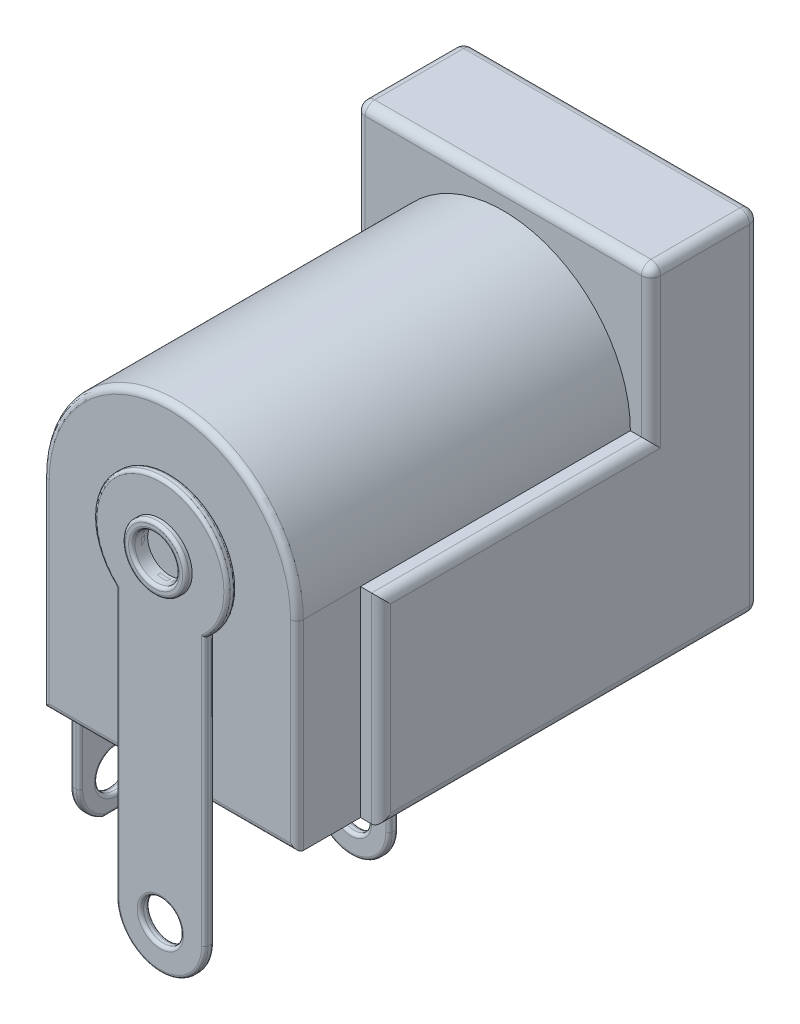
from build123d import *

# Parameters (mm, degrees)
SZKIC1_W                    = 9.3
SZKIC1_H                    = 11
DODANIE_WYCI_GNI_CIE1_DEPTH = 13.9
SZKIC2_W                    = 2.749255813
SZKIC2_H                    = 13.524079228
WYTNIJ_WYCI_GNI_CIE1_DEPTH  = 0.65
WYTNIJ_WYCI_GNI_CIE2_DEPTH  = 10.5
SZKIC4_R                    = 3.55
WYTNIJ_WYCI_GNI_CIE3_DEPTH  = 11.9
SZKIC5_R                    = 0.63
SZKIC5_R_2                  = 0.7
DODANIE_WYCI_GNI_CIE2_DEPTH = 0.3
SZKIC6_R                    = 1
DODANIE_WYCI_GNI_CIE3_DEPTH = 10
ZAOKR_GLENIE1_R             = 0.4
DODANIE_WYCI_GNI_CIE4_DEPTH = 1.3
ZAOKR_GLENIE2_R             = 0.5
ZAOKR_GLENIE3_R             = 0.3
ZAOKR_GLENIE4_R             = 0.2
ZAOKR_GLENIE5_R             = 0.1
SZKIC8_R                    = 1
SZKIC8_R_2                  = 0.7
DODANIE_WYCI_GNI_CIE5_DEPTH = 0.5
ZAOKR_GLENIE6_R             = 0.1
SZKIC9_R                    = 0.63
DODANIE_WYCI_GNI_CIE6_DEPTH = 0.3
ZAOKR_GLENIE7_R             = 0.1
DODANIE_WYCI_GNI_CIE7_DEPTH = 20.3
SZKIC11_OUTSIDE_W           = 27.84
SZKIC11_OUTSIDE_H           = 23.64
SZKIC11_OUTSIDE_R           = 0.63
WYTNIJ_WYCI_GNI_CIE4_DEPTH  = 20.3
ZAOKR_GLENIE8_R             = 0.1


with BuildPart() as part:
    # Szkic1 → Dodanie-wyciągnięcie1 (new body)
    with BuildSketch(Plane.XY):
        Rectangle(SZKIC1_W, SZKIC1_H)
    extrude(amount=DODANIE_WYCI_GNI_CIE1_DEPTH)

    # Szkic2 → Wytnij-wyciągnięcie1 (cut)
    with BuildSketch(Plane(origin=(4.65, 0, 0), x_dir=(0, 0, -1), z_dir=(1, 0, 0))):
        with Locations((-13.274627907, 1.262039614)):
            Rectangle(SZKIC2_W, SZKIC2_H)
    wytnij_wyci_gni_cie1 = extrude(amount=-WYTNIJ_WYCI_GNI_CIE1_DEPTH, mode=Mode.SUBTRACT)

    # Lustro1: Wytnij-wyciągnięcie1 across plane
    add(wytnij_wyci_gni_cie1.mirror(Plane(origin=(0, 0, 0), x_dir=(0, 0, 1), z_dir=(1, 0, 0))), mode=Mode.SUBTRACT)

    # Szkic3 → Wytnij-wyciągnięcie2 (cut)
    with BuildSketch(Plane.XY.offset(13.9)):
        with BuildLine():
            Line((-4, 0.8), (-6.611766209, 0.8))
            Line((-6.611766209, 0.8), (-6.611766209, 8.429628799))
            Line((-6.611766209, 8.429628799), (6.415013524, 8.429628799))
            Line((6.415013524, 8.429628799), (6.415013524, 0.8))
            Line((6.415013524, 0.8), (4, 0.8))
            ThreePointArc((4, 0.8), (0, 4.8), (-4, 0.8))
        make_face()
    extrude(amount=-WYTNIJ_WYCI_GNI_CIE2_DEPTH, mode=Mode.SUBTRACT)

    # Szkic4 → Wytnij-wyciągnięcie3 (cut)
    with BuildSketch(Plane(origin=(0, 0, 0), x_dir=(-1, 0, 0), z_dir=(0, 0, -1))):
        with Locations((0, 0.8)):
            Circle(SZKIC4_R)
    extrude(amount=-WYTNIJ_WYCI_GNI_CIE3_DEPTH, mode=Mode.SUBTRACT)

    # Zaokrąglenie2
    zaokr_glenie2_edges = [part.edges().sort_by_distance(p)[0] for p in [
        (3.55, 0.8, 0),
    ]]
    fillet(zaokr_glenie2_edges, radius=ZAOKR_GLENIE2_R)

    # Zaokrąglenie3
    zaokr_glenie3_edges = [part.edges().sort_by_distance(p)[0] for p in [
        (4.65, -5.5, 5.95),
        (4.65, -2.35, 11.9),
        (-4.65, -5.5, 5.95),
        (-4.65, -2.35, 11.9),
        (0, 5.5, 0),
        (4.65, 0, 0),
        (0, -5.5, 0),
        (-4.65, 0, 0),
        (4.65, 5.5, 1.7),
        (4.65, 3.15, 3.4),
        (-4.65, 5.5, 1.7),
        (4.65, 0.8, 7.65),
        (-4.65, 0.8, 7.65),
        (0, 5.5, 3.4),
        (-4.65, 3.15, 3.4),
    ]]
    fillet(zaokr_glenie3_edges, radius=ZAOKR_GLENIE3_R)

    # Zaokrąglenie4
    zaokr_glenie4_edges = [part.edges().sort_by_distance(p)[0] for p in [
        (0, -5.5, 13.9),
        (-4, -2.35, 13.9),
        (4, -2.35, 13.9),
        (0, 4.8, 13.9),
    ]]
    fillet(zaokr_glenie4_edges, radius=ZAOKR_GLENIE4_R)

    # Szkic8 → Dodanie-wyciągnięcie5 (add)
    with BuildSketch(Plane.XY.offset(13.9)):
        with Locations((0, 0.8)):
            Circle(SZKIC8_R)
        with Locations((0, 0.8)):
            Circle(SZKIC8_R_2, mode=Mode.SUBTRACT)
    extrude(amount=DODANIE_WYCI_GNI_CIE5_DEPTH)

    # Zaokrąglenie6
    zaokr_glenie6_edges = [part.edges().sort_by_distance(p)[0] for p in [
        (-1, 0.8, 14.4),
        (-0.7, 0.8, 14.4),
    ]]
    fillet(zaokr_glenie6_edges, radius=ZAOKR_GLENIE6_R)


with BuildPart() as body_2:
    # Szkic5 → Dodanie-wyciągnięcie2 (new body)
    with BuildSketch(Plane.XY.offset(13.9)):
        with BuildLine():
            Line((1.4, -5.5), (-1.4, -5.5))
            Line((-1.4, -5.5), (-1.4, -9.2))
            ThreePointArc((-1.4, -9.2), (0, -10.6), (1.4, -9.2))
            Line((1.4, -9.2), (1.4, -5.5))
        make_face()
        with Locations((0, -9.2)):
            Circle(SZKIC5_R, mode=Mode.SUBTRACT)
        with BuildLine():
            ThreePointArc((1.4, -0.765247584), (0, 2.9), (-1.4, -0.765247584))
            Line((-1.4, -0.765247584), (-1.4, -5.5))
            Line((-1.4, -5.5), (1.4, -5.5))
            Line((1.4, -5.5), (1.4, -0.765247584))
        make_face()
        with Locations((0, 0.8)):
            Circle(SZKIC5_R_2, mode=Mode.SUBTRACT)
    extrude(amount=DODANIE_WYCI_GNI_CIE2_DEPTH)

    # Zaokrąglenie5
    zaokr_glenie5_edges = [body_2.edges().sort_by_distance(p)[0] for p in [
        (-1.4, -4.982623792, 13.9),
        (-0.63, -9.2, 13.9),
        (-1.4, -4.982623792, 14.2),
        (0, -10.6, 14.2),
        (1.4, -4.982623792, 14.2),
        (0, 2.9, 14.2),
        (-0.7, 0.8, 14.2),
        (-0.63, -9.2, 14.2),
        (-0.7, 0.8, 13.9),
        (0, 2.9, 13.9),
        (1.4, -4.982623792, 13.9),
        (0, -10.6, 13.9),
    ]]
    fillet(zaokr_glenie5_edges, radius=ZAOKR_GLENIE5_R)


with BuildPart() as body_3:
    # Szkic6 → Dodanie-wyciągnięcie3 (new body)
    with BuildSketch(Plane(origin=(0, 0, 11.9), x_dir=(-1, 0, 0), z_dir=(0, 0, -1))):
        with Locations((0, 0.8)):
            Circle(SZKIC6_R)
    extrude(amount=DODANIE_WYCI_GNI_CIE3_DEPTH)

    # Zaokrąglenie1
    zaokr_glenie1_edges = [body_3.edges().sort_by_distance(p)[0] for p in [
        (1, 0.8, 1.9),
    ]]
    fillet(zaokr_glenie1_edges, radius=ZAOKR_GLENIE1_R)


with BuildPart() as body_4:
    # Szkic7 → Dodanie-wyciągnięcie4 (new body, symmetric)
    with BuildSketch(Plane(origin=(0, 0, 0), x_dir=(0, 0, -1), z_dir=(1, 0, 0))):
        with BuildLine():
            Line((-2.4, -1.451343329), (-2.4, -1.574639266))
            ThreePointArc((-2.4, -1.574639266), (-2.445080666, -1.701130372), (-2.56, -1.770598445))
            ThreePointArc((-2.56, -1.770598445), (-2.580211742, -1.769131782), (-2.6, -1.764762524))
            ThreePointArc((-2.6, -1.764762524), (-2.672249722, -1.714264448), (-2.7, -1.630598445))
            Line((-2.7, -1.630598445), (-2.7, -1.575949306))
            Line((-2.7, -1.575949306), (-5.15, -1.065247584))
            Line((-5.15, -1.065247584), (-7.6, -1.575949306))
            Line((-7.6, -1.575949306), (-7.6, -1.909704781))
            Line((-7.6, -1.909704781), (-7.9, -1.909704781))
            Line((-7.9, -1.909704781), (-7.9, -1.480474967))
            Line((-7.9, -1.480474967), (-7.9, -1.337476183))
            Line((-7.9, -1.337476183), (-5.178520727, -0.771182266))
            ThreePointArc((-5.178520727, -0.771182266), (-5.15, -0.768246369), (-5.121479273, -0.771182266))
            Line((-5.121479273, -0.771182266), (-2.571479273, -1.301794239))
            Line((-2.571479273, -1.301794239), (-2.511479273, -1.314279227))
            ThreePointArc((-2.511479273, -1.314279227), (-2.431388532, -1.36300563), (-2.4, -1.451343329))
        make_face()
    extrude(amount=DODANIE_WYCI_GNI_CIE4_DEPTH, both=True)


with BuildPart() as body_5:
    # Szkic9 → Dodanie-wyciągnięcie6 (new body)
    with BuildSketch(Plane(origin=(0, 0, 7.9), x_dir=(-1, 0, 0), z_dir=(0, 0, -1))):
        with BuildLine():
            Line((-1.2, -5.5), (-1.2, -9.2))
            ThreePointArc((-1.2, -9.2), (0, -10.4), (1.2, -9.2))
            Line((1.2, -9.2), (1.2, -5.5))
            Line((1.2, -5.5), (1.12, -5.5))
            Line((1.12, -5.5), (-1.12, -5.5))
            Line((-1.12, -5.5), (-1.2, -5.5))
        make_face()
        with Locations((0, -9.2)):
            Circle(SZKIC9_R, mode=Mode.SUBTRACT)
        with Locations((0, -9.2)):
            Circle(SZKIC9_R)
        with BuildLine():
            ThreePointArc((0.55, -9.2), (0.38890873, -8.81109127), (0, -8.65))
            ThreePointArc((0, -8.65), (-0.38890873, -9.58890873), (0.55, -9.2))
        make_face(mode=Mode.SUBTRACT)
    extrude(amount=-DODANIE_WYCI_GNI_CIE6_DEPTH)

    # Zaokrąglenie7
    zaokr_glenie7_edges = [body_5.edges().sort_by_distance(p)[0] for p in [
        (0, -10.4, 8.2),
        (-1.2, -7.35, 8.2),
        (0, -5.5, 8.2),
        (0.55, -9.2, 8.2),
        (1.2, -7.35, 8.2),
        (0.55, -9.2, 7.9),
        (0, -5.5, 7.9),
        (-1.2, -7.35, 7.9),
        (0, -10.4, 7.9),
        (1.2, -7.35, 7.9),
    ]]
    fillet(zaokr_glenie7_edges, radius=ZAOKR_GLENIE7_R)


with BuildPart() as body_6:
    # Szkic10 → Dodanie-wyciągnięcie7 (new body)
    with BuildSketch(Plane(origin=(0, 0, 0), x_dir=(-1, 0, 0), z_dir=(0, 0, -1))):
        with BuildLine():
            Line((4.85, -9.2), (4.85, -10.32))
            Line((4.85, -10.32), (5.15, -10.32))
            Line((5.15, -10.32), (5.15, -9.2))
            Line((5.15, -9.2), (5.15, -1.7))
            ThreePointArc((5.15, -1.7), (5.003553391, -1.346446609), (4.65, -1.2))
            Line((4.65, -1.2), (4.65, -1.28))
            Line((4.65, -1.28), (4.65, -1.403613054))
            Line((4.65, -1.403613054), (4.65, -1.5))
            ThreePointArc((4.65, -1.5), (4.797213595, -1.676393202), (4.85, -1.9))
            Line((4.85, -1.9), (4.85, -9.2))
        make_face()
    extrude(amount=-DODANIE_WYCI_GNI_CIE7_DEPTH)

    # Szkic11 outside → Wytnij-wyciągnięcie4 (cut)
    with BuildSketch(Plane.ZY.offset(5.15)):
        with Locations((10.15, -2.55)):
            Rectangle(SZKIC11_OUTSIDE_W, SZKIC11_OUTSIDE_H)
        with BuildLine():
            Line((11.9, -9.2), (11.9, -1.7))
            Line((11.9, -1.7), (11.9, -1.28))
            Line((11.9, -1.28), (11.9, -1.2))
            Line((11.9, -1.2), (11.82, -1.2))
            Line((11.82, -1.2), (11.4, -1.2))
            Line((11.4, -1.2), (9.58, -1.2))
            Line((9.58, -1.2), (9.5, -1.2))
            Line((9.5, -1.2), (9.5, -1.28))
            Line((9.5, -1.28), (9.5, -1.7))
            Line((9.5, -1.7), (9.5, -9.2))
            ThreePointArc((9.5, -9.2), (10.7, -10.4), (11.9, -9.2))
        make_face(mode=Mode.SUBTRACT)
        with Locations((10.7, -9.2)):
            Circle(SZKIC11_OUTSIDE_R)
    extrude(amount=-WYTNIJ_WYCI_GNI_CIE4_DEPTH, mode=Mode.SUBTRACT)

    # Zaokrąglenie8
    zaokr_glenie8_edges = [body_6.edges().sort_by_distance(p)[0] for p in [
        (-4.85, -10.32, 10.7),
        (-4.85, -5.55, 11.9),
        (-4.85, -9.879346811, 11.689185478),
        (-4.85, -5.55, 9.5),
        (-4.85, -9.879346811, 9.710814522),
        (-5.15, -10.32, 10.7),
        (-5.15, -9.879346811, 11.689185478),
        (-5.15, -9.879346811, 9.710814522),
        (-5.003553391, -1.346446609, 9.5),
        (-5.15, -5.45, 9.5),
        (-4.797213595, -1.676393202, 9.5),
        (-5.15, -5.45, 11.9),
        (-5.003553391, -1.346446609, 11.9),
        (-4.797213595, -1.676393202, 11.9),
        (-4.85, -9.2, 10.07),
        (-5.15, -9.2, 10.07),
    ]]
    fillet(zaokr_glenie8_edges, radius=ZAOKR_GLENIE8_R)


solid = Compound([part.part, body_2.part, body_3.part, body_4.part, body_5.part, body_6.part])
